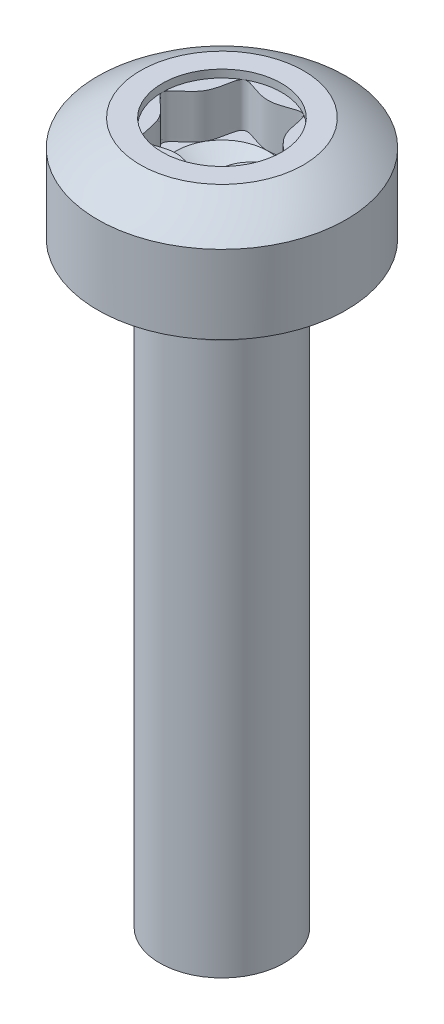
from build123d import *

# Parameters (mm, degrees)
RECESS_CUT_EXTRUDE1_DEPTH = 1.04
SKETCH7_R                 = 1.2
RECESS_CUT_EXTRUDE2_DEPTH = 0.156


with BuildPart() as part:
    # Sketch1 → BODY (revolve)
    with BuildSketch(Plane.XY, mode=Mode.PRIVATE) as body_sk:
        Polygon((0, 0), (1.25, 0), (1.25, 12), (2.5, 12), (2.5, 14.1), (0, 14.1), align=None)
    revolve(body_sk.sketch.rotate(Axis((0, 0, 0), (0, 1, 0)), 90), axis=Axis((0, 0, 0), (0, 1, 0)))

    # Sketch2 → HEAD-CUT (revolve, cut)
    with BuildSketch(Plane.XY, mode=Mode.PRIVATE) as head_cut_sk:
        with BuildLine():
            ThreePointArc((4, 10.452501001), (2.828427125, 13.280928126), (0, 14.452501001))
            Line((0, 14.452501001), (0, 14.934662571))
            Line((0, 14.934662571), (4, 14.934662571))
            Line((4, 14.934662571), (4, 10.452501001))
        make_face()
    revolve(head_cut_sk.sketch.rotate(Axis((0, 0, 0), (0, 1, 0)), 90), axis=Axis((0, 0, 0), (0, 1, 0)), mode=Mode.SUBTRACT)

    # Sketch4 → GAP (revolve, cut)
    with BuildSketch(Plane.XY, mode=Mode.PRIVATE) as gap_sk:
        with BuildLine():
            Line((-1.25, 11.1), (-1.188645175, 11.9))
            ThreePointArc((-1.188645175, 11.9), (-1.20311675, 11.959943063), (-1.25, 12))
            Line((-1.25, 12), (-1.25, 11.1))
        make_face()
    revolve(gap_sk.sketch.rotate(Axis((0, 0, 0), (0, 1, 0)), 270), axis=Axis((0, 0, 0), (0, 1, 0)), mode=Mode.SUBTRACT)

    # Sketch5 → Recess-Cut-Extrude1 (cut)
    with BuildSketch(Plane(origin=(0, 14.1, 0), x_dir=(-1, 0, 0), z_dir=(0, 1, 0))):
        with BuildLine():
            add(Edge.make_bspline(
                [(0, 0.923076923), (-0.246244913, 0.923076923), (-0.738734739, 1.279526102), (-0.645061043, 0.372426167), (-1.477469478, 0), (-0.645061043, -0.372426167), (-0.738734739, -1.279526102), (0, -0.744852334), (0.738734739, -1.279526102), (0.645061043, -0.372426167), (1.477469478, 0), (0.645061043, 0.372426167), (0.738734739, 1.279526102), (0.246244913, 0.923076923), (0, 0.923076923)],
                knots=[0, 0, 0, 0, 0.083333333, 0.166666667, 0.25, 0.333333333, 0.416666667, 0.5, 0.583333333, 0.666666667, 0.75, 0.833333333, 0.916666667, 1, 1, 1, 1], degree=3))
        make_face()
    extrude(amount=-RECESS_CUT_EXTRUDE1_DEPTH, mode=Mode.SUBTRACT)

    # Sketch3 → DRILL-CUT (revolve, cut)
    with BuildSketch(Plane.XY, mode=Mode.PRIVATE) as drill_cut_sk:
        Polygon((0, 12.52706129), (0.923076923, 13.06), (0, 13.06), align=None)
    revolve(drill_cut_sk.sketch.rotate(Axis((0, 0, 0), (0, 1, 0)), 270), axis=Axis((0, 0, 0), (0, 1, 0)), mode=Mode.SUBTRACT)

    # Sketch7 → Recess-Cut-Extrude2 (cut)
    with BuildSketch(Plane(origin=(0, 14.1, 0), x_dir=(-1, 0, 0), z_dir=(0, 1, 0))):
        with Locations(Location((0, 0, 0), (0, 0, 90))):
            Circle(SKETCH7_R)
    extrude(amount=-RECESS_CUT_EXTRUDE2_DEPTH, mode=Mode.SUBTRACT)


solid = part.part
